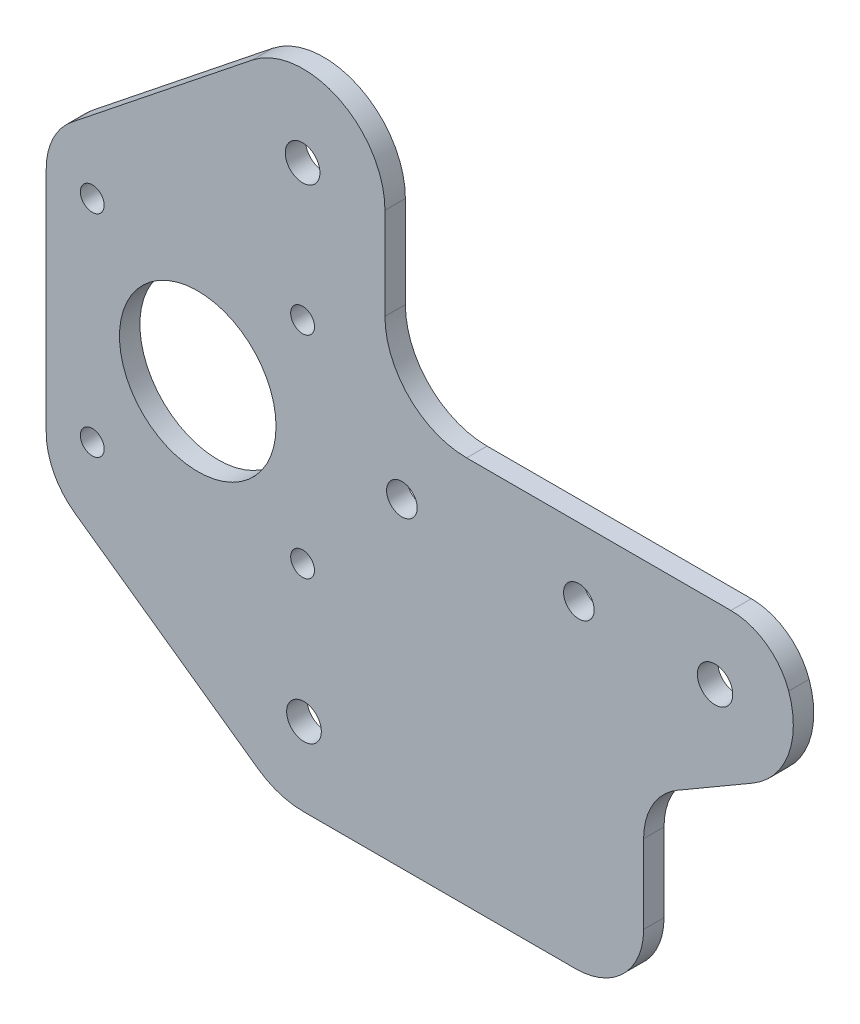
from build123d import *

# Parameters (mm, degrees)
SKETCH1_R           = 2.6
SKETCH1_R_2         = 2.25
SKETCH1_R_3         = 11.5
SKETCH1_R_4         = 2.55
SKETCH1_R_5         = 2.250902383
SKETCH1_R_6         = 1.75
BOSS_EXTRUDE1_DEPTH = 3


with BuildPart() as part:
    # Sketch1 → Boss-Extrude1 (new body)
    with BuildSketch(Plane.XY):
        with BuildLine():
            Line((-17.667944903, 51.26061463), (-17.667944903, 17.69061463))
            ThreePointArc((-17.667944903, 17.69061463), (-16.55108605, 13.098251038), (-13.449984231, 9.531691833))
            Line((-13.449984231, 9.531691833), (13.449984231, -9.531691833))
            ThreePointArc((13.449984231, -9.531691833), (16.610185866, -11.106844514), (20.099329458, -11.648930616))
            Line((20.099329458, -11.648930616), (60.099329458, -11.648930616))
            ThreePointArc((60.099329458, -11.648930616), (67.17039727, -8.719998428), (70.099329458, -1.648930616))
            Line((70.099329458, -1.648930616), (70.099329458, 9.901069384))
            ThreePointArc((70.099329458, 9.901069384), (71.430361969, 14.885946781), (75.069129992, 18.543817403))
            Line((75.069129992, 18.543817403), (86.131847457, 24.98247272))
            ThreePointArc((86.131847457, 24.98247272), (91.358121472, 31.21181519), (91.413130529, 39.342966504))
            ThreePointArc((91.413130529, 39.342966504), (88.124648594, 43.697057203), (82.924988705, 45.351069384))
            Line((82.924988705, 45.351069384), (44.094988705, 45.351069384))
            ThreePointArc((44.094988705, 45.351069384), (35.609707331, 48.86578801), (32.094988705, 57.351069384))
            Line((32.094988705, 57.351069384), (32.094988705, 70.851069384))
            ThreePointArc((32.094988705, 70.851069384), (25.300553143, 81.663196782), (12.611305558, 80.231607031))
            Line((12.611305558, 80.231607031), (-13.904347525, 59.077729336))
            ThreePointArc((-13.904347525, 59.077729336), (-16.678051068, 55.598584995), (-17.667944903, 51.26061463))
        make_face()
        with Locations((80.59476396, 34.780670506)):
            Circle(SKETCH1_R, mode=Mode.SUBTRACT)
        with Locations((60.58476396, 35.351069384)):
            Circle(SKETCH1_R_2, mode=Mode.SUBTRACT)
        with Locations((4.592055097, 35.34829978)):
            Circle(SKETCH1_R_3, mode=Mode.SUBTRACT)
        with Locations((19.994988754, 70.850970592)):
            Circle(SKETCH1_R_4, mode=Mode.SUBTRACT)
        with Locations((34.584765763, 35.341387282)):
            Circle(SKETCH1_R_5, mode=Mode.SUBTRACT)
        with Locations((20.199329409, -0.149029408)):
            Circle(SKETCH1_R_4, mode=Mode.SUBTRACT)
        with Locations((19.992055097, 19.851069384)):
            Circle(SKETCH1_R_6, mode=Mode.SUBTRACT)
        with Locations((-10.907944903, 19.851069384)):
            Circle(SKETCH1_R_6, mode=Mode.SUBTRACT)
        with Locations((-10.907944903, 50.851069384)):
            Circle(SKETCH1_R_6, mode=Mode.SUBTRACT)
        with Locations((19.992055097, 50.851069384)):
            Circle(SKETCH1_R_6, mode=Mode.SUBTRACT)
    extrude(amount=BOSS_EXTRUDE1_DEPTH)


solid = part.part
